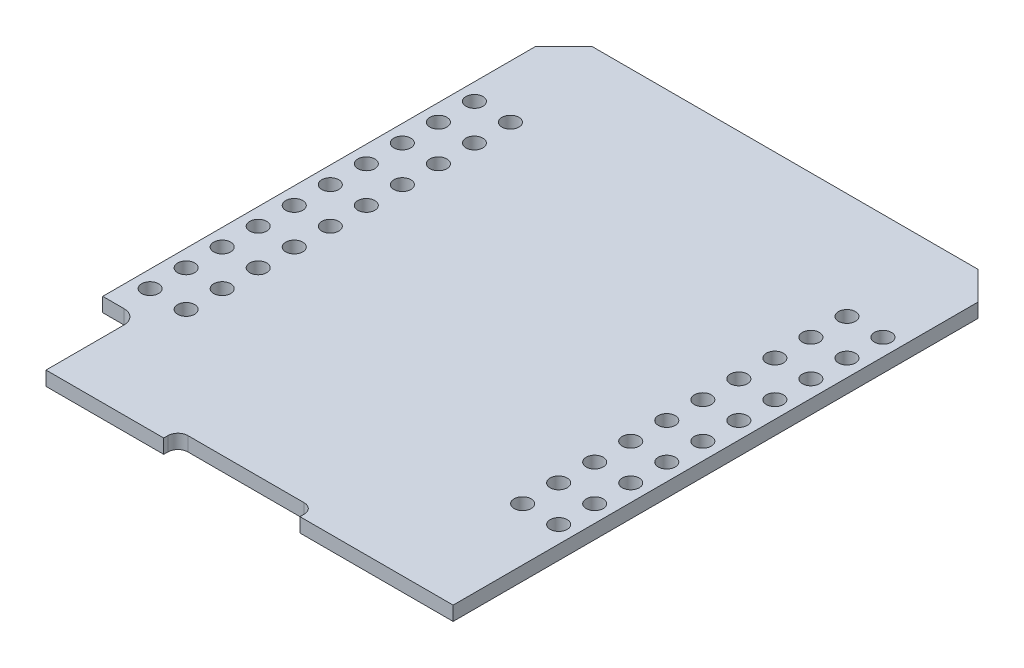
from build123d import *

# Parameters (mm, degrees)
BOSS_EXTRU_1_DEPTH      = 1
ESQUISSE2_R             = 0.6
ENL_V_MAT_EXTRU_1_DEPTH = 1


with BuildPart() as part:
    # Esquisse1 → Boss.-Extru.1 (new body)
    with BuildSketch(Plane(origin=(0, 0, 0), x_dir=(1, 0, 0), z_dir=(0, 1, 0))):
        with BuildLine():
            Line((-13.1, 0), (-13.1, 5.5))
            ThreePointArc((-13.1, 5.5), (-13.392893219, 6.207106781), (-14.1, 6.5))
            Line((-14.1, 6.5), (-15.6, 6.5))
            Line((-15.6, 6.5), (-15.6, 37))
            Line((-15.6, 37), (-13.6, 39))
            Line((-13.6, 39), (13.6, 39))
            Line((13.6, 39), (15.6, 37))
            Line((15.6, 37), (15.6, 0))
            Line((15.6, 0), (4.8, 0))
            Line((4.8, 0), (4.8, 0.3))
            ThreePointArc((4.8, 0.3), (4.594974747, 0.794974747), (4.1, 1))
            Line((4.1, 1), (-4.1, 1))
            ThreePointArc((-4.1, 1), (-4.594974747, 0.794974747), (-4.8, 0.3))
            Line((-4.8, 0.3), (-4.8, 0))
            Line((-4.8, 0), (-13.1, 0))
        make_face()
    extrude(amount=BOSS_EXTRU_1_DEPTH)

    # Esquisse2 → Enlèv. mat.-Extru.1 (cut)
    with BuildSketch(Plane(origin=(0, 1, 0), x_dir=(1, 0, 0), z_dir=(0, 1, 0))):
        with Locations((14.4, 31.5)):
            Circle(ESQUISSE2_R)
        with Locations((11.86, 31.5)):
            Circle(ESQUISSE2_R)
        with Locations((11.86, 28.96)):
            Circle(ESQUISSE2_R)
        with Locations((11.86, 26.42)):
            Circle(ESQUISSE2_R)
        with Locations((11.86, 23.88)):
            Circle(ESQUISSE2_R)
        with Locations((11.86, 21.34)):
            Circle(ESQUISSE2_R)
        with Locations((11.86, 18.8)):
            Circle(ESQUISSE2_R)
        with Locations((11.86, 16.26)):
            Circle(ESQUISSE2_R)
        with Locations((11.86, 13.72)):
            Circle(ESQUISSE2_R)
        with Locations((11.86, 11.18)):
            Circle(ESQUISSE2_R)
        with Locations((11.86, 8.64)):
            Circle(ESQUISSE2_R)
        with Locations((14.4, 28.96)):
            Circle(ESQUISSE2_R)
        with Locations((14.4, 26.42)):
            Circle(ESQUISSE2_R)
        with Locations((14.4, 23.88)):
            Circle(ESQUISSE2_R)
        with Locations((14.4, 21.34)):
            Circle(ESQUISSE2_R)
        with Locations((14.4, 18.8)):
            Circle(ESQUISSE2_R)
        with Locations((14.4, 16.26)):
            Circle(ESQUISSE2_R)
        with Locations((14.4, 13.72)):
            Circle(ESQUISSE2_R)
        with Locations((14.4, 11.18)):
            Circle(ESQUISSE2_R)
        with Locations((14.4, 8.64)):
            Circle(ESQUISSE2_R)
        with Locations((-14.4, 8.64)):
            Circle(ESQUISSE2_R)
        with Locations((-14.4, 11.18)):
            Circle(ESQUISSE2_R)
        with Locations((-14.4, 13.72)):
            Circle(ESQUISSE2_R)
        with Locations((-14.4, 16.26)):
            Circle(ESQUISSE2_R)
        with Locations((-14.4, 18.8)):
            Circle(ESQUISSE2_R)
        with Locations((-14.4, 21.34)):
            Circle(ESQUISSE2_R)
        with Locations((-14.4, 23.88)):
            Circle(ESQUISSE2_R)
        with Locations((-14.4, 26.42)):
            Circle(ESQUISSE2_R)
        with Locations((-14.4, 28.96)):
            Circle(ESQUISSE2_R)
        with Locations((-11.86, 8.64)):
            Circle(ESQUISSE2_R)
        with Locations((-11.86, 11.18)):
            Circle(ESQUISSE2_R)
        with Locations((-11.86, 13.72)):
            Circle(ESQUISSE2_R)
        with Locations((-11.86, 16.26)):
            Circle(ESQUISSE2_R)
        with Locations((-11.86, 18.8)):
            Circle(ESQUISSE2_R)
        with Locations((-11.86, 21.34)):
            Circle(ESQUISSE2_R)
        with Locations((-11.86, 23.88)):
            Circle(ESQUISSE2_R)
        with Locations((-11.86, 26.42)):
            Circle(ESQUISSE2_R)
        with Locations((-11.86, 28.96)):
            Circle(ESQUISSE2_R)
        with Locations((-11.86, 31.5)):
            Circle(ESQUISSE2_R)
        with Locations((-14.4, 31.5)):
            Circle(ESQUISSE2_R)
    extrude(amount=-ENL_V_MAT_EXTRU_1_DEPTH, mode=Mode.SUBTRACT)


solid = part.part
